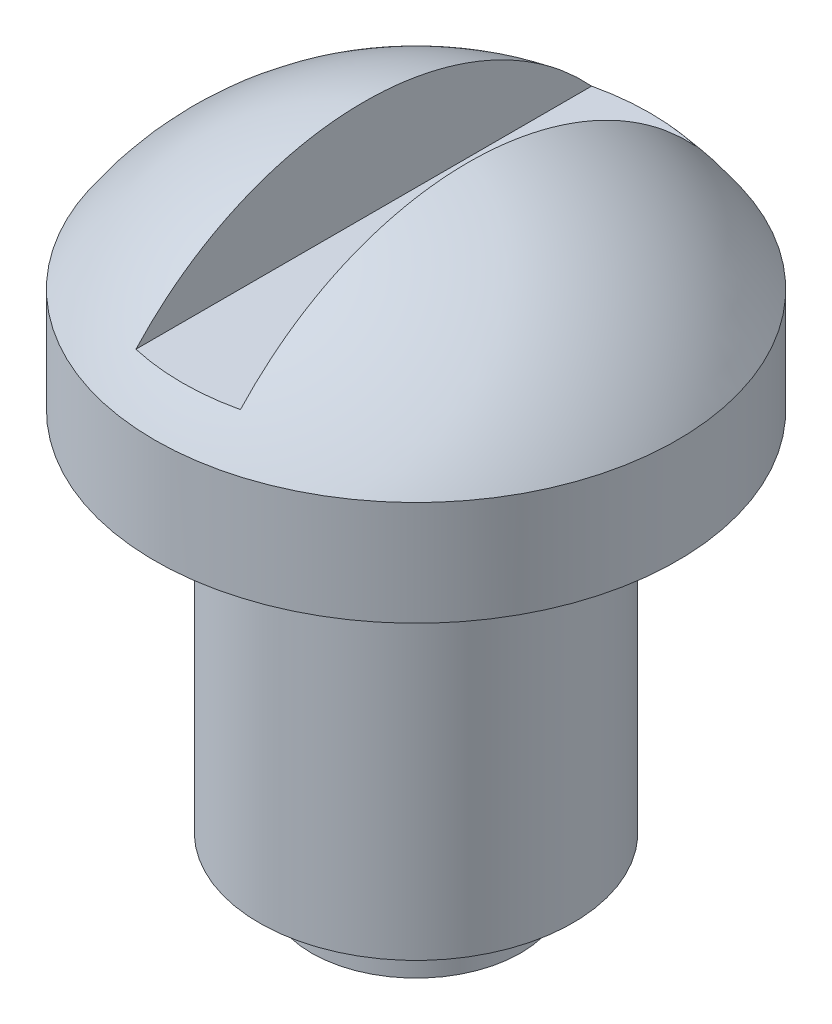
from build123d import *

# Parameters (mm, degrees)
SKETCH5_W          = 2
SKETCH5_H          = 14
CUT_EXTRUDE1_DEPTH = 2


with BuildPart() as part:
    # Sketch1 → Revolve1 (revolve)
    with BuildSketch(Plane.XY):
        with BuildLine():
            Line((0, 0), (2, 0))
            Line((2, 0), (2, 1))
            Line((2, 1), (3, 1))
            Line((3, 1), (3, 8))
            Line((3, 8), (5, 8))
            Line((5, 8), (5, 10))
            ThreePointArc((5, 10), (2.837274331, 11.970139283), (0, 12.68337521))
            Line((0, 12.68337521), (0, 10))
            Line((0, 10), (0, 0))
        make_face()
    revolve(axis=Axis((0, 10, 0), (0, -1, 0)))

    # Sketch5 → Cut-Extrude1 (cut)
    with BuildSketch(Plane(origin=(0, 12.68337521, 0), x_dir=(1, 0, 0), z_dir=(0, 1, 0))):
        Rectangle(SKETCH5_W, SKETCH5_H)
    extrude(amount=-CUT_EXTRUDE1_DEPTH, mode=Mode.SUBTRACT)


solid = part.part
